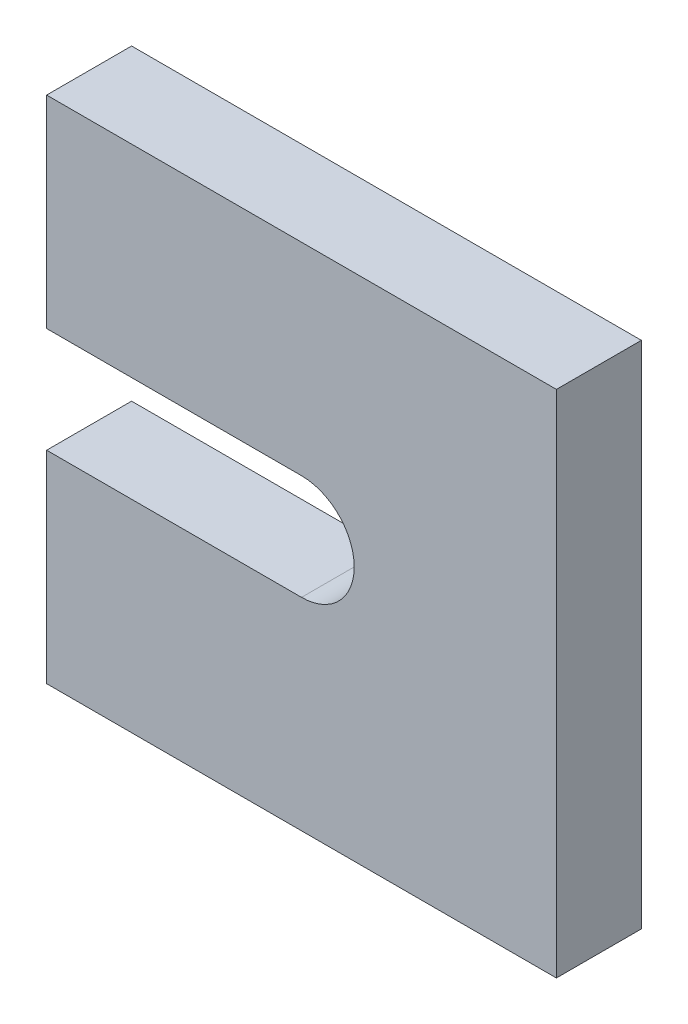
from build123d import *

# Parameters (mm, degrees)
BOSS_EXTRUDE1_DEPTH = 5


with BuildPart() as part:
    # Sketch1 → Boss-Extrude1 (new body)
    with BuildSketch(Plane.XY):
        with BuildLine():
            Line((15, 18.1), (0, 18.1))
            Line((0, 18.1), (0, 30))
            Line((0, 30), (30, 30))
            Line((30, 30), (30, 0))
            Line((30, 0), (0, 0))
            Line((0, 0), (0, 11.9))
            Line((0, 11.9), (15, 11.9))
            ThreePointArc((15, 11.9), (18.1, 15), (15, 18.1))
        make_face()
    extrude(amount=BOSS_EXTRUDE1_DEPTH)


solid = part.part
